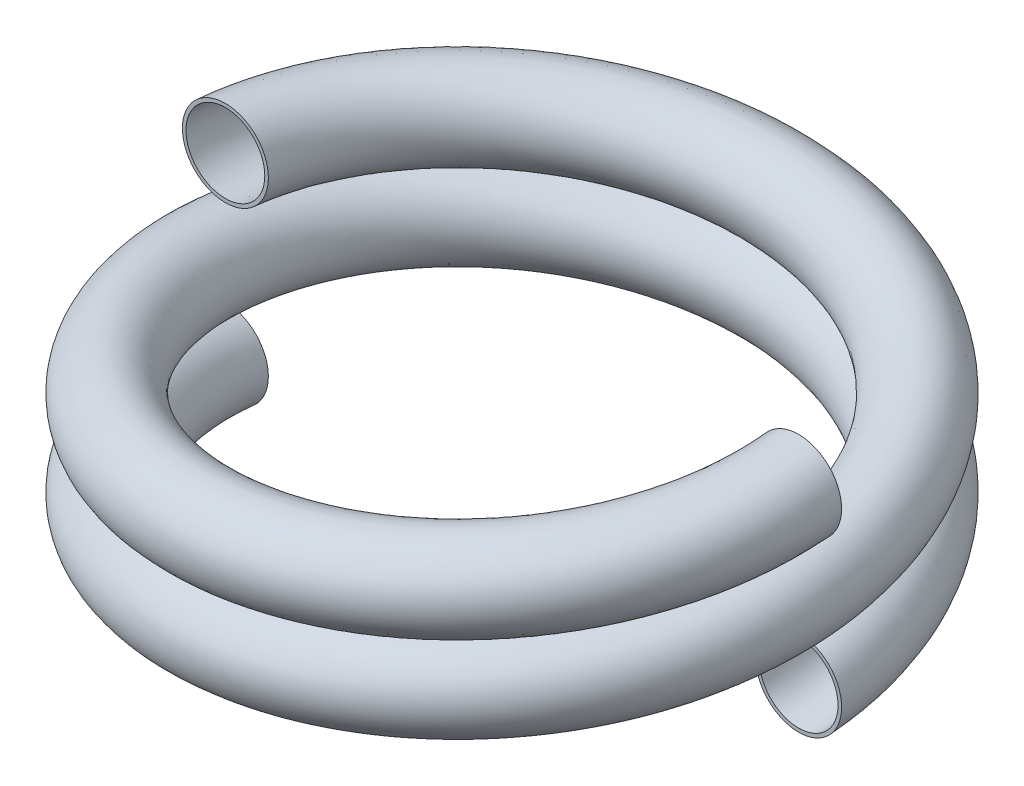
from build123d import *

# Parameters (mm, degrees)
SWEEP1_PITCH       = 609.6
SWEEP1_HEIGHT      = 609.6
SWEEP1_RADIUS      = 1016
SWEEP1_START_ANGLE = 90
SKETCH4_R          = 152.4
SKETCH4_R_2        = 139.7
SWEEP4_PITCH       = 609.6
SWEEP4_HEIGHT      = 609.6
SWEEP4_RADIUS      = 1016
SWEEP4_START_ANGLE = -90
SKETCH5_R          = 152.4
SKETCH5_R_2        = 139.7


with BuildPart() as part:
    # Sweep1: sweep along a helix
    with BuildLine() as sweep1_path:
        add(Helix(SWEEP1_PITCH, SWEEP1_HEIGHT, SWEEP1_RADIUS, center=(0, 0, 0), direction=(0, 1, 0), mode=Mode.PRIVATE).rotate(Axis((0, 0, 0), (0, 1, 0)), SWEEP1_START_ANGLE))
    # Sketch4 → Sweep1 (sweep)
    with BuildSketch(Plane.XY):
        with Locations((1016, 0)):
            Circle(SKETCH4_R)
        with Locations((1016, 0)):
            Circle(SKETCH4_R_2, mode=Mode.SUBTRACT)
    sweep(path=sweep1_path.line, is_frenet=True)


with BuildPart() as body_2:
    # Sweep4: sweep along a helix
    with BuildLine() as sweep4_path:
        add(Helix(SWEEP4_PITCH, SWEEP4_HEIGHT, SWEEP4_RADIUS, center=(0, 0, 0), direction=(0, 1, 0), mode=Mode.PRIVATE).rotate(Axis((0, 0, 0), (0, 1, 0)), SWEEP4_START_ANGLE))
    # Sketch5 → Sweep4 (sweep)
    with BuildSketch(Plane.XY):
        with Locations((-1016, 0)):
            Circle(SKETCH5_R)
        with Locations((-1016, 0)):
            Circle(SKETCH5_R_2, mode=Mode.SUBTRACT)
    sweep(path=sweep4_path.line, is_frenet=True)


solid = Compound([part.part, body_2.part])
